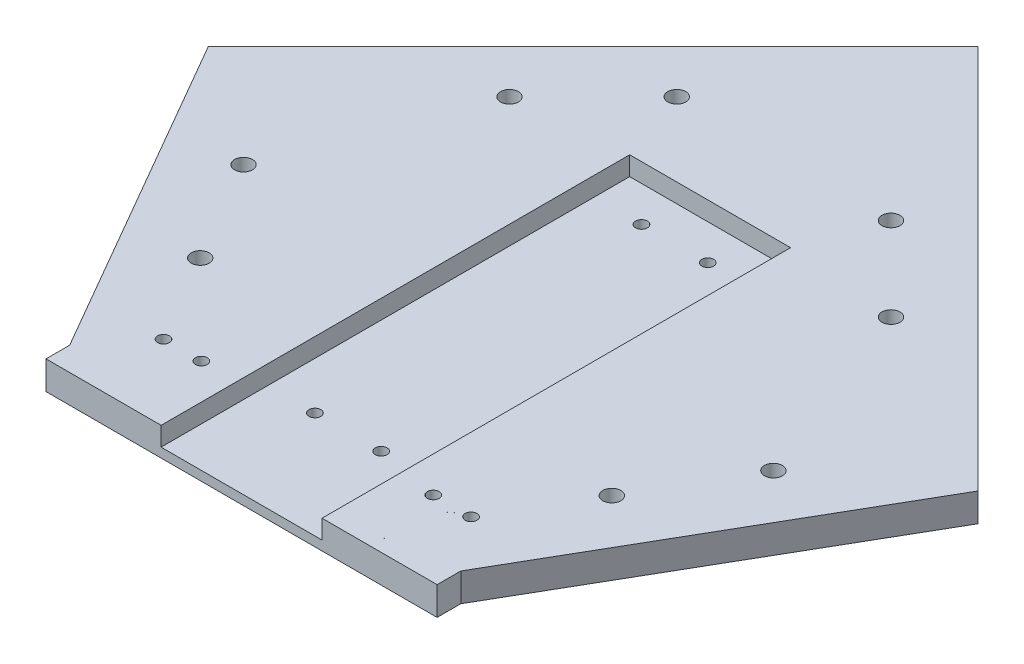
from build123d import *

# Parameters (mm, degrees)
BOSS_EXTRUDE1_DEPTH = 6
SKETCH2_W           = 34
SKETCH2_H           = 99
CUT_EXTRUDE1_DEPTH  = 4
SKETCH4_R           = 1.9
CUT_EXTRUDE2_DEPTH  = 7
SKETCH5_R           = 1.8
SKETCH5_R_2         = 1.25
CUT_EXTRUDE3_DEPTH  = 10
SKETCH6_R           = 1.25
CUT_EXTRUDE4_DEPTH  = 10
SKETCH7_R           = 1.25
CUT_EXTRUDE5_DEPTH  = 10
SKETCH8_R           = 1.8
SKETCH8_R_2         = 1.25
BOSS_EXTRUDE2_DEPTH = 6


with BuildPart() as part:
    # Sketch1 → Boss-Extrude1 (new body)
    with BuildSketch(Plane(origin=(0, 0, 0), x_dir=(1, 0, 0), z_dir=(0, 1, 0))):
        Polygon((-41.317279836, -84.379169784), (-41.317279836, -89.379169784), (41.317279836, -89.379169784), (41.317279836, -84.379169784), (81.317279836, -15.097137481), (0, 66.220142355), (-81.317279836, -15.097137481), align=None)
    extrude(amount=BOSS_EXTRUDE1_DEPTH)

    # Sketch2 → Cut-Extrude1 (cut)
    with BuildSketch(Plane(origin=(0, 6, 0), x_dir=(1, 0, 0), z_dir=(0, 1, 0))):
        with Locations((0.002279836, -39.879169784)):
            Rectangle(SKETCH2_W, SKETCH2_H)
    extrude(amount=-CUT_EXTRUDE1_DEPTH, mode=Mode.SUBTRACT)

    # Sketch4 → Cut-Extrude2 (cut, through all)
    with BuildSketch(Plane(origin=(0, 6, 0), x_dir=(1, 0, 0), z_dir=(0, 1, 0))):
        with Locations((-22.627416998, 25.207949047)):
            Circle(SKETCH4_R)
        with Locations((-40.305086528, 7.530279517)):
            Circle(SKETCH4_R)
        with Locations((-55.979629628, -32.983234986)):
            Circle(SKETCH4_R)
        with Locations((-43.479629628, -54.633870081)):
            Circle(SKETCH4_R)
        with Locations((43.479629628, -54.633870081)):
            Circle(SKETCH4_R)
        with Locations((55.979629628, -32.983234986)):
            Circle(SKETCH4_R)
        with Locations((22.627416998, 25.207949047)):
            Circle(SKETCH4_R)
        with Locations((40.305086528, 7.530279517)):
            Circle(SKETCH4_R)
    extrude(amount=-CUT_EXTRUDE2_DEPTH, mode=Mode.SUBTRACT)

    # Sketch5 → Cut-Extrude3 (cut)
    with BuildSketch(Plane(origin=(0, 6, 0), x_dir=(1, 0, 0), z_dir=(0, 1, 0))):
        with Locations((-28.497720164, -73.379169784)):
            Circle(SKETCH5_R)
        with Locations((28.502279836, -73.379169784)):
            Circle(SKETCH5_R)
        with Locations((26.002279836, -86.379169784)):
            Circle(SKETCH5_R_2)
        with Locations((-25.997720164, -86.379169784)):
            Circle(SKETCH5_R_2)
    extrude(amount=-CUT_EXTRUDE3_DEPTH, mode=Mode.SUBTRACT)

    # Sketch6 → Cut-Extrude4 (cut)
    with BuildSketch(Plane(origin=(0, 2, 0), x_dir=(1, 0, 0), z_dir=(0, 1, 0))):
        with Locations((7.002279836, 2.120830216)):
            Circle(SKETCH6_R)
        with Locations((-6.997720164, 2.120830216)):
            Circle(SKETCH6_R)
        with Locations((-6.997720164, -66.879169784)):
            Circle(SKETCH6_R)
        with Locations((7.002279836, -66.879169784)):
            Circle(SKETCH6_R)
    extrude(amount=-CUT_EXTRUDE4_DEPTH, mode=Mode.SUBTRACT)

    # Sketch7 → Cut-Extrude5 (cut)
    with BuildSketch(Plane(origin=(0, 6, 0), x_dir=(1, 0, 0), z_dir=(0, 1, 0))):
        with Locations((-32.497720164, -73.379169784)):
            Circle(SKETCH7_R)
        with Locations((-24.497720164, -73.379169784)):
            Circle(SKETCH7_R)
    cut_extrude5 = extrude(amount=-CUT_EXTRUDE5_DEPTH, mode=Mode.SUBTRACT)

    # Mirror1: Cut-Extrude5 across plane
    add(cut_extrude5.mirror(Plane(origin=(0, 0, 0), x_dir=(0, 0, 1), z_dir=(1, 0, 0))), mode=Mode.SUBTRACT)

    # Sketch8 → Boss-Extrude2 (add)
    with BuildSketch(Plane(origin=(0, 6, 0), x_dir=(1, 0, 0), z_dir=(0, 1, 0))):
        with Locations((-28.497720164, -73.379169784)):
            Circle(SKETCH8_R)
        with Locations((-25.997720164, -86.379169784)):
            Circle(SKETCH8_R_2)
    boss_extrude2 = extrude(amount=-BOSS_EXTRUDE2_DEPTH)

    # Mirror2: Boss-Extrude2 across plane
    add(boss_extrude2.mirror(Plane(origin=(0, 0, 0), x_dir=(0, 0, 1), z_dir=(1, 0, 0))))


solid = part.part
